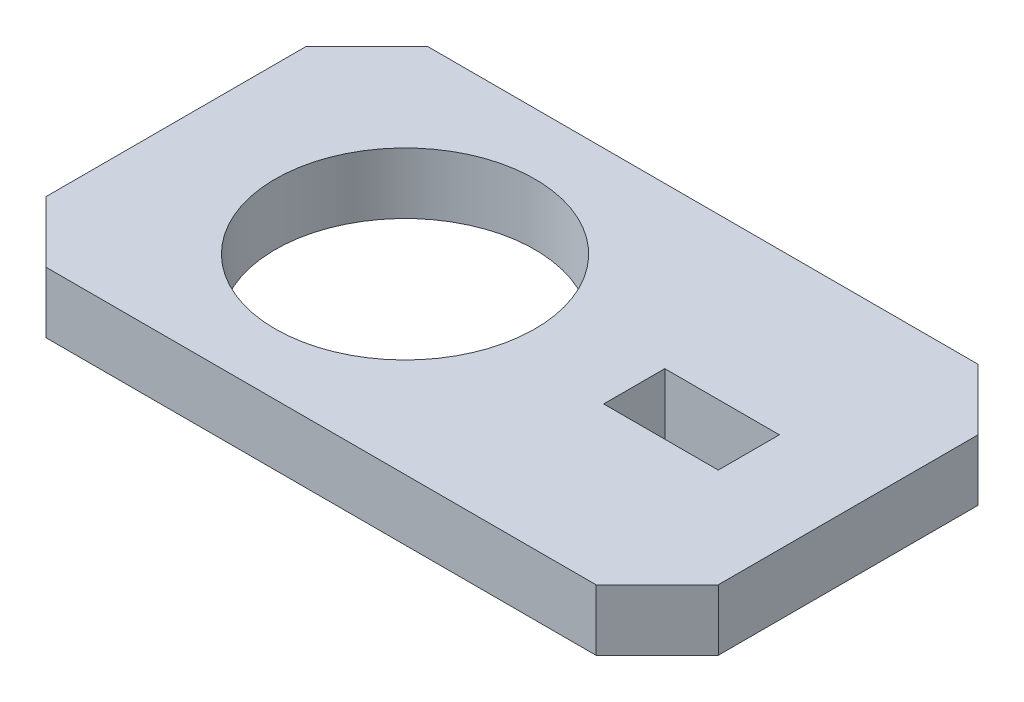
from build123d import *

# Parameters (mm, degrees)
SKETCH1_W           = 44
SKETCH1_H           = 25
SKETCH1_R           = 8.5
SKETCH1_W_2         = 7.5
SKETCH1_H_2         = 4
BOSS_EXTRUDE1_DEPTH = 4
CHAMFER1_SIZE       = 4


with BuildPart() as part:
    # Sketch1 → Boss-Extrude1 (new body)
    with BuildSketch(Plane(origin=(0, 0, 0), x_dir=(1, 0, 0), z_dir=(0, 1, 0))):
        with Locations((22, 12.5)):
            Rectangle(SKETCH1_W, SKETCH1_H)
        with Locations((15, 12.5)):
            Circle(SKETCH1_R, mode=Mode.SUBTRACT)
        with Locations((33.75, 12.5)):
            Rectangle(SKETCH1_W_2, SKETCH1_H_2, mode=Mode.SUBTRACT)
    extrude(amount=BOSS_EXTRUDE1_DEPTH)

    # Chamfer1
    chamfer1_edges = [part.edges().sort_by_distance(p)[0] for p in [
        (0, 2, -25),
        (44, 2, -25),
        (44, 2, 0),
        (0, 2, 0),
    ]]
    chamfer(chamfer1_edges, length=CHAMFER1_SIZE)


solid = part.part
